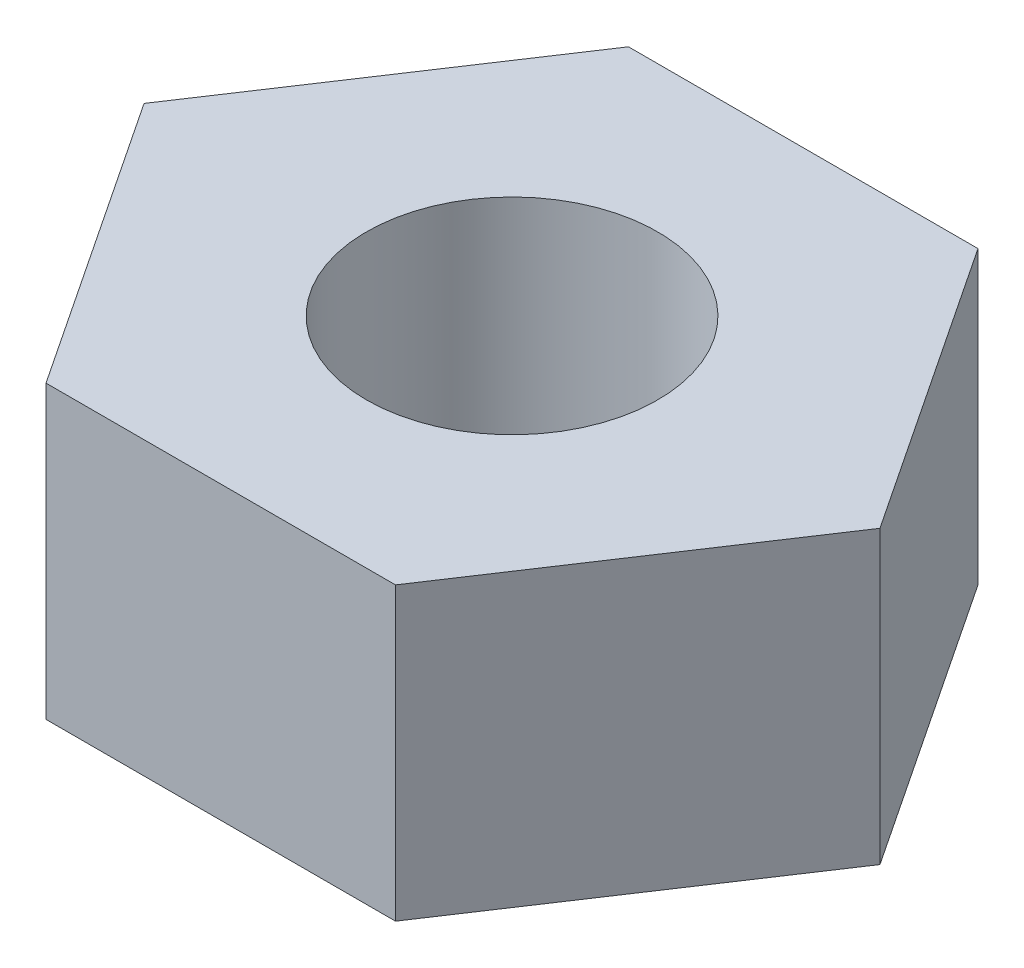
from build123d import *

# Parameters (mm, degrees)
SKETCH1_R           = 5
BOSS_EXTRUDE1_DEPTH = 10


with BuildPart() as part:
    # Sketch1 → Boss-Extrude1 (new body)
    with BuildSketch(Plane(origin=(0, 0, 0), x_dir=(1, 0, 0), z_dir=(0, 1, 0))):
        Polygon((-6.001750419, 10), (5.998249581, 10), (12.631499161, 0), (5.998249581, -10), (-6.001750419, -10), (-12.635, 0), align=None)
        Circle(SKETCH1_R, mode=Mode.SUBTRACT)
    extrude(amount=BOSS_EXTRUDE1_DEPTH)


solid = part.part
